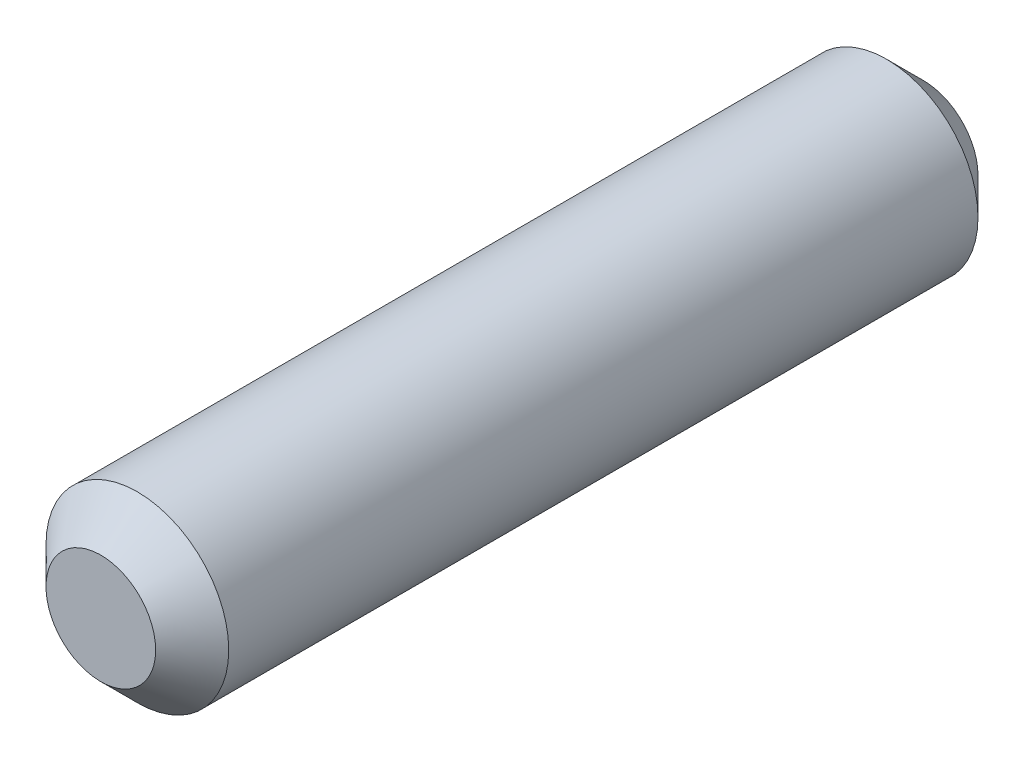
from build123d import *

# Parameters (mm, degrees)
SKETCH1_R           = 5
BOSS_EXTRUDE1_DEPTH = 45
CHAMFER1_SIZE       = 2


with BuildPart() as part:
    # Sketch1 → Boss-Extrude1 (new body)
    with BuildSketch(Plane.XY):
        Circle(SKETCH1_R)
    extrude(amount=BOSS_EXTRUDE1_DEPTH)

    # Chamfer1
    chamfer1_edges = [part.edges().sort_by_distance(p)[0] for p in [
        (-5, 0, 0),
        (-5, 0, 45),
    ]]
    chamfer(chamfer1_edges, length=CHAMFER1_SIZE)


solid = part.part
